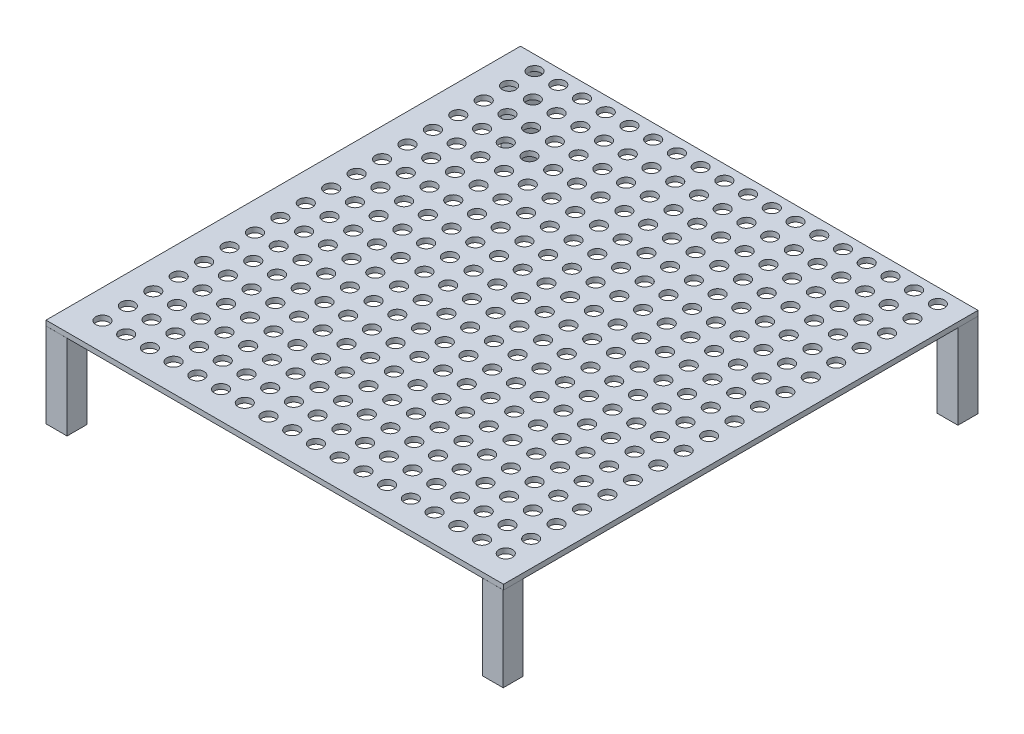
from build123d import *

# Parameters (mm, degrees)
SKETCH1_W           = 270
SKETCH1_H           = 280
BOSS_EXTRUDE1_DEPTH = 3
SKETCH2_R           = 4
CUT_EXTRUDE1_DEPTH  = 132.5
LPATTERN1_COUNT     = 18
LPATTERN1_PITCH     = 15
SKETCH3_W           = 12.292627745
SKETCH3_H           = 11.697686649
BOSS_EXTRUDE2_DEPTH = 50


with BuildPart() as part:
    # Sketch1 → Boss-Extrude1 (new body)
    with BuildSketch(Plane(origin=(0, 0, 0), x_dir=(1, 0, 0), z_dir=(0, 1, 0))):
        with Locations((1.596999302, -2.953009045)):
            Rectangle(SKETCH1_W, SKETCH1_H)
    extrude(amount=BOSS_EXTRUDE1_DEPTH)

    # Sketch2 → Cut-Extrude1 (cut)
    with BuildSketch(Plane(origin=(0, 3, 0), x_dir=(1, 0, 0), z_dir=(0, 1, 0))):
        with Locations((-116.490205779, 128.447761087)):
            Circle(SKETCH2_R)
        with Locations((-102.490205779, 128.447761087)):
            Circle(SKETCH2_R)
        with Locations((-88.490205779, 128.447761087)):
            Circle(SKETCH2_R)
        with Locations((-74.490205779, 128.447761087)):
            Circle(SKETCH2_R)
        with Locations((-60.490205779, 128.447761087)):
            Circle(SKETCH2_R)
        with Locations((-46.490205779, 128.447761087)):
            Circle(SKETCH2_R)
        with Locations((-32.490205779, 128.447761087)):
            Circle(SKETCH2_R)
        with Locations((-18.490205779, 128.447761087)):
            Circle(SKETCH2_R)
        with Locations((-4.490205779, 128.447761087)):
            Circle(SKETCH2_R)
        with Locations((9.509794221, 128.447761087)):
            Circle(SKETCH2_R)
        with Locations((23.509794221, 128.447761087)):
            Circle(SKETCH2_R)
        with Locations((37.509794221, 128.447761087)):
            Circle(SKETCH2_R)
        with Locations((51.509794221, 128.447761087)):
            Circle(SKETCH2_R)
        with Locations((65.509794221, 128.447761087)):
            Circle(SKETCH2_R)
        with Locations((79.509794221, 128.447761087)):
            Circle(SKETCH2_R)
        with Locations((93.509794221, 128.447761087)):
            Circle(SKETCH2_R)
        with Locations((107.509794221, 128.447761087)):
            Circle(SKETCH2_R)
        with Locations((121.509794221, 128.447761087)):
            Circle(SKETCH2_R)
    cut_extrude1 = extrude(amount=-CUT_EXTRUDE1_DEPTH, mode=Mode.SUBTRACT)

    # LPattern1: Cut-Extrude1 ×18
    with Locations(*[(0, 0, i * LPATTERN1_PITCH) for i in range(1, LPATTERN1_COUNT)]):
        add(cut_extrude1, mode=Mode.SUBTRACT)

    # Sketch3 → Boss-Extrude2 (add)
    with BuildSketch(Plane.XZ):
        with Locations((130.288207922, 137.123787746)):
            Rectangle(SKETCH3_W, SKETCH3_H)
        with Locations((-127.094209319, 137.123787746)):
            Rectangle(SKETCH3_W, SKETCH3_H)
        with Locations((130.288207922, -131.217769657)):
            Rectangle(SKETCH3_W, SKETCH3_H)
        with Locations((-127.094209319, -131.217769657)):
            Rectangle(SKETCH3_W, SKETCH3_H)
    extrude(amount=BOSS_EXTRUDE2_DEPTH)


solid = part.part
